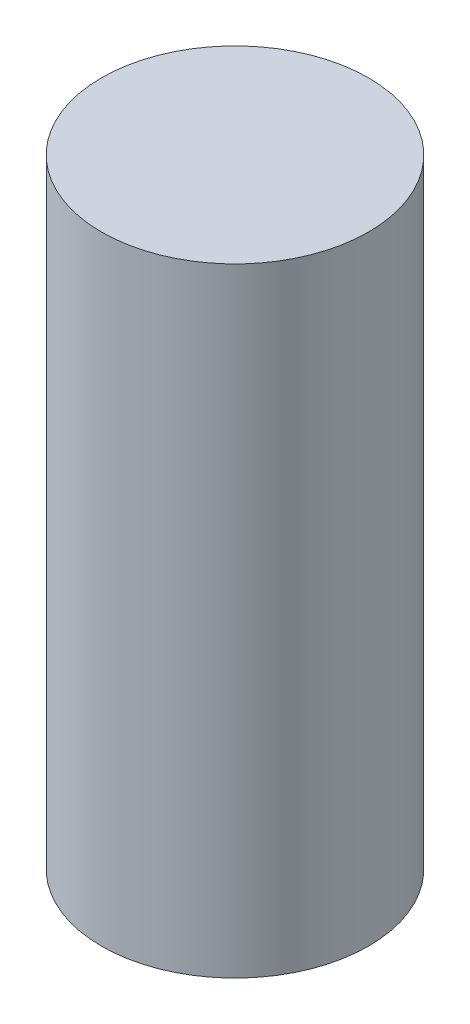
from build123d import *

# Parameters (mm, degrees)
SKETCH1_R           = 60.325
BOSS_EXTRUDE1_DEPTH = 279.4


with BuildPart() as part:
    # Sketch1 → Boss-Extrude1 (new body)
    with BuildSketch(Plane(origin=(0, 0, 0), x_dir=(1, 0, 0), z_dir=(0, 1, 0))):
        Circle(SKETCH1_R)
    extrude(amount=BOSS_EXTRUDE1_DEPTH)


solid = part.part
